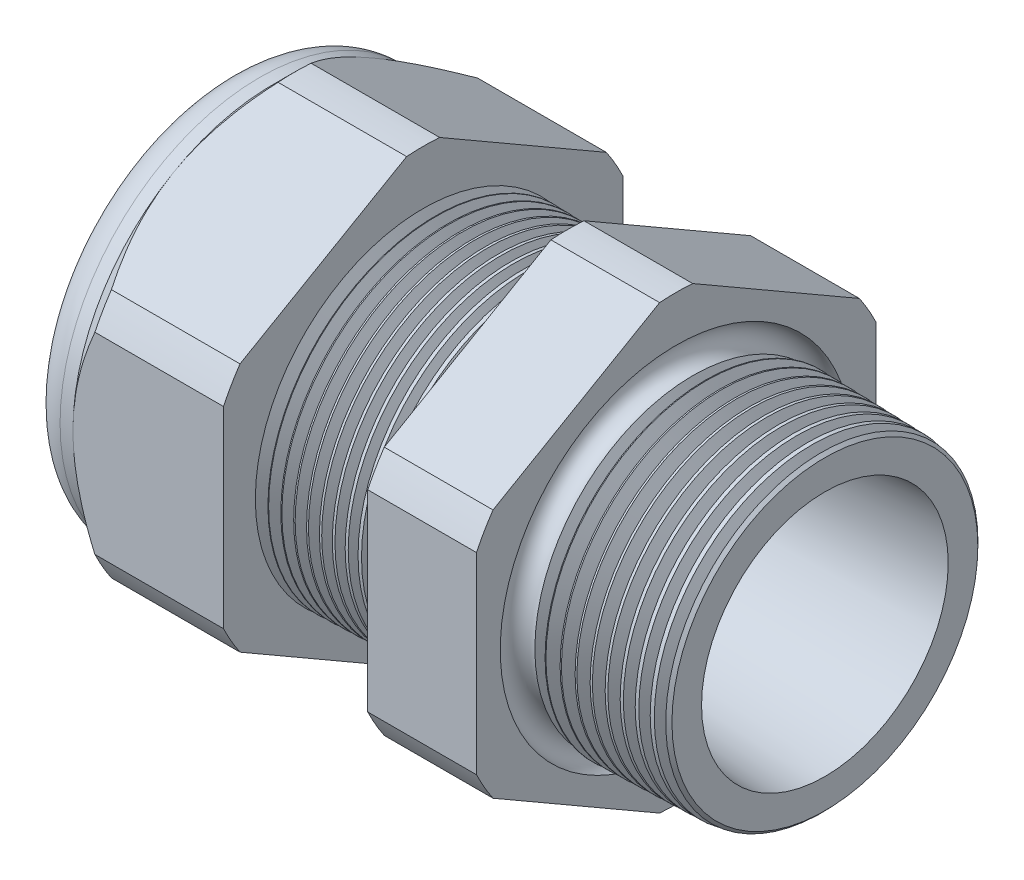
from build123d import *

# Parameters (mm, degrees)
SKETCH12_OUTSIDE_W = 65.04
SKETCH12_OUTSIDE_H = 65.04
CUT_EXTRUDE2_DEPTH = 34.014
FILLET4_R          = 2.032
SKETCH19_OUTSIDE_W = 39.986
SKETCH19_OUTSIDE_H = 42.612
SKETCH19_OUTSIDE_R = 11.938
CUT_EXTRUDE3_DEPTH = 1.999996
CUT_EXTRUDE3_DRAFT = -45
CHAMFER1_SIZE      = 0.260919487
CHAMFER1_SIZE2     = 0.254
SKETCH21_R         = 5.969
PLUG_DEPTH         = 6.35
SKETCH22_R         = 5.715
CUT_EXTRUDE4_DEPTH = 0.508
SKETCH27_R         = 2.032
PLUGHOLES_DEPTH    = 36.306
CIRPATTERN1_COUNT  = 3
LPATTERN1_COUNT    = 11
LPATTERN1_PITCH    = 0.762
LPATTERN2_COUNT    = 10
LPATTERN2_PITCH    = 0.889
SKETCH32_R         = 0.889


with BuildPart() as part:
    # Sketch10 → Revolve2 (revolve)
    with BuildSketch(Plane.XY, mode=Mode.PRIVATE) as revolve2_sk:
        Polygon((-34.798, 5.969), (-22.998, 5.969), (1.016, 7.372171279), (1.016, 9.404171279), (-7.874, 9.636964122), (-7.874, 23.876), (-14.374, 23.876), (-14.374, 9.807172612), (-22.998, 10.033), (-22.998, 23.876), (-31.998, 23.876), (-31.998, 11.938), (-34.798, 11.938), align=None)
    revolve(revolve2_sk.sketch.rotate(Axis((0, 0, 0), (-1, 0, 0)), 90), axis=Axis((0, 0, 0), (-1, 0, 0)))  # turned: the seam where the file's is

    # Sketch12 outside → Cut-Extrude2 (cut, through all)
    with BuildSketch(Plane.ZY.offset(31.998)):
        Rectangle(SKETCH12_OUTSIDE_W, SKETCH12_OUTSIDE_H)
        with BuildLine():
            Line((-0.98819228, 13.214281948), (-10.94980772, 7.462940592))
            ThreePointArc((-10.94980772, 7.462940592), (-11.47585851, 6.62559), (-11.938, 5.751341356))
            Line((-11.938, 5.751341356), (-11.938, -5.751341356))
            ThreePointArc((-11.938, -5.751341356), (-11.47585851, -6.62559), (-10.94980772, -7.462940592))
            Line((-10.94980772, -7.462940592), (-0.98819228, -13.214281948))
            ThreePointArc((-0.98819228, -13.214281948), (0, -13.25118), (0.98819228, -13.214281948))
            Line((0.98819228, -13.214281948), (10.94980772, -7.462940592))
            ThreePointArc((10.94980772, -7.462940592), (11.47585851, -6.62559), (11.938, -5.751341356))
            Line((11.938, -5.751341356), (11.938, 5.751341356))
            ThreePointArc((11.938, 5.751341356), (11.47585851, 6.62559), (10.94980772, 7.462940592))
            Line((10.94980772, 7.462940592), (0.98819228, 13.214281948))
            ThreePointArc((0.98819228, 13.214281948), (0, 13.25118), (-0.98819228, 13.214281948))
        make_face(mode=Mode.SUBTRACT)
    extrude(amount=-CUT_EXTRUDE2_DEPTH, mode=Mode.SUBTRACT)

    # Fillet4
    fillet4_edges = [part.edges().sort_by_distance(p)[0] for p in [
        (-34.798, 0, 11.938),
    ]]
    fillet(fillet4_edges, radius=FILLET4_R)


with BuildPart() as cut_extrude3_tool:
    # Sketch19 outside → Cut-Extrude3 (with draft: the straight prism first)
    with BuildSketch(Plane.ZY.offset(31.998)):
        Rectangle(SKETCH19_OUTSIDE_W, SKETCH19_OUTSIDE_H)
        Circle(SKETCH19_OUTSIDE_R, mode=Mode.SUBTRACT)
    extrude(amount=-CUT_EXTRUDE3_DEPTH)
    # Cut-Extrude3: the draft: its side faces are tilted about the plane it starts from
    cut_extrude3_sides = [cut_extrude3_tool.faces().sort_by_distance(p)[0] for p in [
        (-30.998002, -21.306, 0),
        (-30.998002, 0, 19.993),
        (-30.998002, 21.306, 0),
        (-30.998002, 0, -19.993),
        (-30.998002, 0, -11.938),
    ]]
    draft(cut_extrude3_sides, Plane.ZY.offset(31.998), CUT_EXTRUDE3_DRAFT)


with BuildPart() as part_1:
    add(part.part)

    # Cut-Extrude3: cut by cut_extrude3_tool
    add(cut_extrude3_tool.part, mode=Mode.SUBTRACT)

    # Chamfer1
    chamfer1_edges = [part_1.edges().sort_by_distance(p)[0] for p in [
        (1.016, 0, 9.404171279),
    ]]
    chamfer1_side = [part_1.faces().sort_by_distance(p)[0] for p in [
        (1.016, 0, 7.638161411),
    ]]
    chamfer(chamfer1_edges, length=CHAMFER1_SIZE, length2=CHAMFER1_SIZE2, reference=chamfer1_side[0])

    # Sketch29 → Cut-Revolve1 (revolve, cut)
    with BuildSketch(Plane.XY, mode=Mode.PRIVATE) as cut_revolve1_sk:
        Polygon((-22.998, 10.033), (-22.265016419, 10.013806149), (-22.648130572, 9.388620673), align=None)
    cut_revolve1 = revolve(cut_revolve1_sk.sketch.rotate(Axis((0, 0, 0), (-1, 0, 0)), 90), axis=Axis((0, 0, 0), (-1, 0, 0)), mode=Mode.SUBTRACT)  # turned: the seam where the file's is

    # LPattern1: Cut-Revolve1 ×11
    with Locations(*[(i * LPATTERN1_PITCH, 0, 0) for i in range(1, LPATTERN1_COUNT)]):
        add(cut_revolve1, mode=Mode.SUBTRACT)

    # Sketch30 → Cut-Revolve2 (revolve, cut)
    with BuildSketch(Plane.XY, mode=Mode.PRIVATE) as cut_revolve2_sk:
        Polygon((-7.874, 9.636964122), (-6.994419703, 9.613931502), (-7.454156686, 8.86370893), align=None)
    cut_revolve2 = revolve(cut_revolve2_sk.sketch.rotate(Axis((0, 0, 0), (-1, 0, 0)), 270), axis=Axis((0, 0, 0), (-1, 0, 0)), mode=Mode.SUBTRACT)  # turned: the seam where the file's is

    # LPattern2: Cut-Revolve2 ×10
    with Locations(*[(i * LPATTERN2_PITCH, 0, 0) for i in range(1, LPATTERN2_COUNT)]):
        add(cut_revolve2, mode=Mode.SUBTRACT)

    # Sketch32 → Cut-Revolve3 (revolve, cut)
    with BuildSketch(Plane.XY, mode=Mode.PRIVATE) as cut_revolve3_sk:
        with Locations((-7.747, 9.636964122)):
            Circle(SKETCH32_R)
    revolve(cut_revolve3_sk.sketch.rotate(Axis((0, 0, 0), (-1, 0, 0)), 270), axis=Axis((0, 0, 0), (-1, 0, 0)), mode=Mode.SUBTRACT)  # turned: the seam where the file's is


with BuildPart() as body_2:
    # Sketch21 → plug (new body)
    with BuildSketch(Plane.ZY.offset(34.798)):
        Circle(SKETCH21_R)
    extrude(amount=-PLUG_DEPTH)

    # Sketch22 → Cut-Extrude4 (cut)
    with BuildSketch(Plane.ZY.offset(34.798)):
        Circle(SKETCH22_R)
    extrude(amount=-CUT_EXTRUDE4_DEPTH, mode=Mode.SUBTRACT)

    # Sketch27 → plugholes (cut, through all)
    with BuildSketch(Plane.ZY.offset(34.29)):
        with Locations((-3.674872, 0)):
            Circle(SKETCH27_R)
    plugholes = extrude(amount=-PLUGHOLES_DEPTH, mode=Mode.SUBTRACT)

    # CirPattern1: plugholes ×3 about axis
    cirpattern1_axis = Axis((0, 0, 0), (1, 0, 0))
    for i in range(1, CIRPATTERN1_COUNT):
        add(plugholes.rotate(cirpattern1_axis, i * 360 / CIRPATTERN1_COUNT), mode=Mode.SUBTRACT)


solid = Compound([part_1.part, body_2.part])
